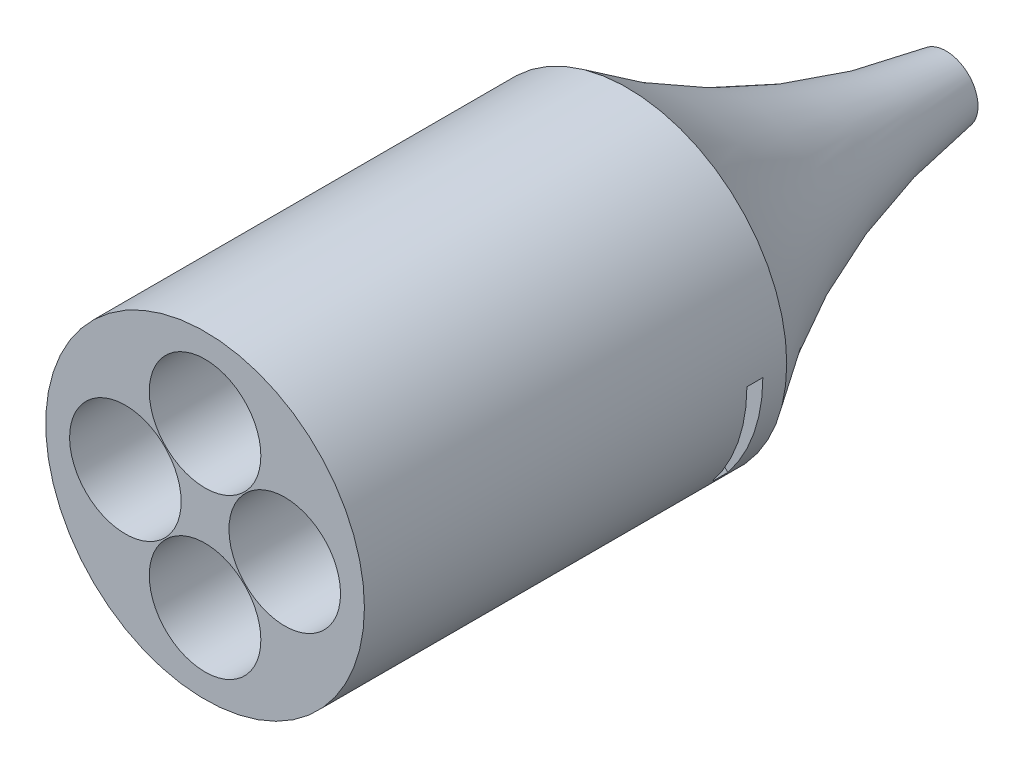
from build123d import *

# Parameters (mm, degrees)
CROQUIS1_R              = 20
SALIENTE_EXTRUIR1_DEPTH = 3
CROQUIS2_R              = 20
CROQUIS2_R_2            = 7
SALIENTE_EXTRUIR2_DEPTH = 50
CROQUIS6_W              = 2
CROQUIS6_H              = 12
CORTAR_EXTRUIR1_DEPTH   = 32


with BuildPart() as part:
    # Croquis1 → Saliente-Extruir1 (new body)
    with BuildSketch(Plane.XY):
        with Locations((-44.21130789, 7.297319347)):
            Circle(CROQUIS1_R)
    extrude(amount=SALIENTE_EXTRUIR1_DEPTH)

    # Croquis2 → Saliente-Extruir2 (add)
    with BuildSketch(Plane.XY.offset(3)):
        with Locations((-44.21130789, 7.297319347)):
            Circle(CROQUIS2_R)
        with Locations((-44.21130789, 17.297319347)):
            Circle(CROQUIS2_R_2, mode=Mode.SUBTRACT)
        with Locations((-34.21130789, 7.297319347)):
            Circle(CROQUIS2_R_2, mode=Mode.SUBTRACT)
        with Locations((-44.21130789, -2.702680653)):
            Circle(CROQUIS2_R_2, mode=Mode.SUBTRACT)
        with Locations((-54.21130789, 7.297319347)):
            Circle(CROQUIS2_R_2, mode=Mode.SUBTRACT)
    extrude(amount=SALIENTE_EXTRUIR2_DEPTH)

    # Croquis4 → Revolución1 (revolve)
    with BuildSketch(Plane(origin=(0, 7.297319347, 0), x_dir=(1, 0, 0), z_dir=(0, 1, 0))):
        with BuildLine():
            Line((-48.21130789, 0), (-64.21130789, 0))
            ThreePointArc((-64.21130789, 0), (-53.677160121, 18.986340893), (-48.21130789, 40))
            Line((-48.21130789, 40), (-48.21130789, 0))
        make_face()
    revolve(axis=Axis((-44.21130789, 7.297319347, 0), (0, 0, -1)))

    # Croquis6 → Cortar-Extruir1 (cut)
    with BuildSketch(Plane(origin=(-11.912562698, 11.676862537, 0), x_dir=(0, 0, -1), z_dir=(0.714136384, -0.700006589, 0))):
        with Locations((-4, -17.736925603)):
            Rectangle(CROQUIS6_W, CROQUIS6_H)
        with Locations((-4, -33.736925603)):
            Rectangle(CROQUIS6_W, CROQUIS6_H)
    extrude(amount=-CORTAR_EXTRUIR1_DEPTH, mode=Mode.SUBTRACT)


solid = part.part
